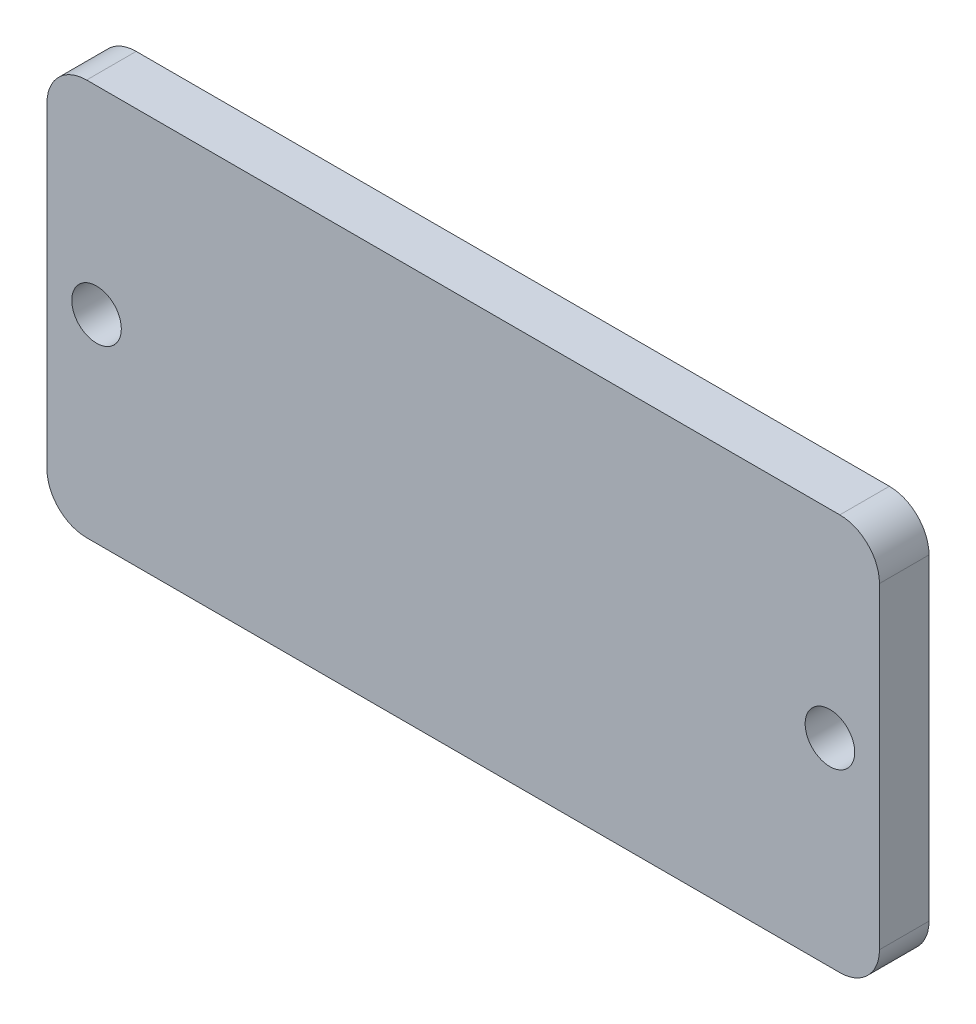
from build123d import *

# Parameters (mm, degrees)
SKETCH1_R           = 1.5875
BOSS_EXTRUDE1_DEPTH = 3.175


with BuildPart() as part:
    # Sketch1 → Boss-Extrude1 (new body)
    with BuildSketch(Plane.XY):
        with BuildLine():
            Line((24.13, -12.7), (-24.13, -12.7))
            ThreePointArc((-24.13, -12.7), (-25.926051224, -11.956051224), (-26.67, -10.16))
            Line((-26.67, -10.16), (-26.67, 10.16))
            ThreePointArc((-26.67, 10.16), (-25.926051224, 11.956051224), (-24.13, 12.7))
            Line((-24.13, 12.7), (24.13, 12.7))
            ThreePointArc((24.13, 12.7), (25.926051224, 11.956051224), (26.67, 10.16))
            Line((26.67, 10.16), (26.67, -10.16))
            ThreePointArc((26.67, -10.16), (25.926051224, -11.956051224), (24.13, -12.7))
        make_face()
        with Locations((-23.495, 0)):
            Circle(SKETCH1_R, mode=Mode.SUBTRACT)
        with Locations((23.495, 0)):
            Circle(SKETCH1_R, mode=Mode.SUBTRACT)
    extrude(amount=BOSS_EXTRUDE1_DEPTH)


solid = part.part
